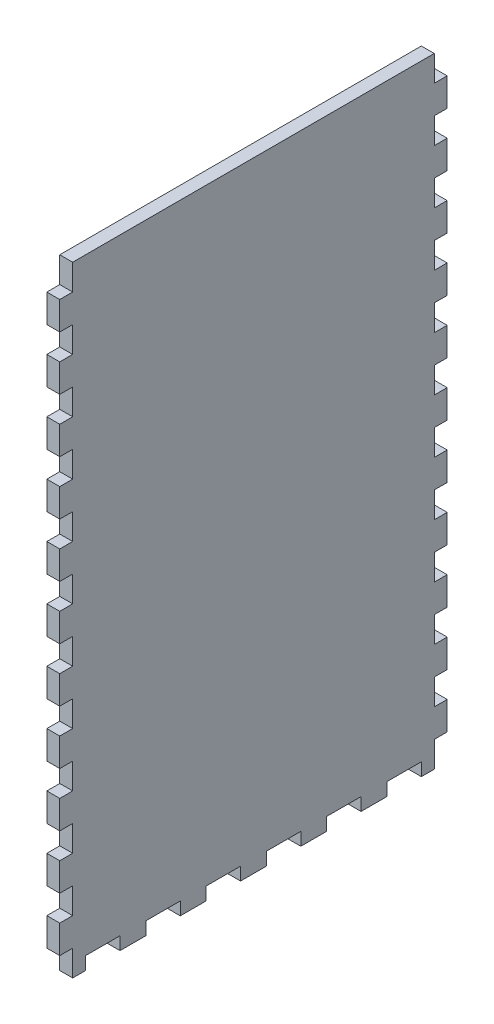
from build123d import *

# Parameters (mm, degrees)
SKETCH1_W           = 508
SKETCH1_H           = 190.5
BOSS_EXTRUDE1_DEPTH = 6.35
SKETCH2_W           = 508
SKETCH2_H           = 190.5
SKETCH2_W_2         = 495.3
SKETCH2_H_2         = 177.8
BOSS_EXTRUDE2_DEPTH = 298.45
SKETCH3_W           = 6.35
SKETCH3_H           = 16.933333333
SKETCH3_H_2         = 16.933333334
CUT_EXTRUDE1_DEPTH  = 12.7
SKETCH4_W           = 6.35
SKETCH4_H           = 15.875
CUT_EXTRUDE2_DEPTH  = 6.35
SKETCH6_W           = 514.801062296
SKETCH6_H           = 254.881465808
CUT_EXTRUDE5_DEPTH  = 305.8
SKETCH5_W           = 6.35
SKETCH5_H           = 16.933333333
SKETCH5_H_2         = 16.933333334
CUT_EXTRUDE6_DEPTH  = 6.35
SKETCH7_W           = 6.35
SKETCH7_H           = 12.7
CUT_EXTRUDE7_DEPTH  = 7.35


with BuildPart() as part:
    # Sketch1 → Boss-Extrude1 (new body)
    with BuildSketch(Plane(origin=(0, 0, 0), x_dir=(1, 0, 0), z_dir=(0, 1, 0))):
        Rectangle(SKETCH1_W, SKETCH1_H)
    extrude(amount=BOSS_EXTRUDE1_DEPTH)

    # Sketch2 → Boss-Extrude2 (add)
    with BuildSketch(Plane(origin=(0, 6.35, 0), x_dir=(1, 0, 0), z_dir=(0, 1, 0))):
        Rectangle(SKETCH2_W, SKETCH2_H)
        Rectangle(SKETCH2_W_2, SKETCH2_H_2, mode=Mode.SUBTRACT)
    extrude(amount=BOSS_EXTRUDE2_DEPTH)

    # Sketch3 → Cut-Extrude1 (cut)
    with BuildSketch(Plane.XY.offset(95.25)):
        with BuildLine():
            Line((-3.302, 283.21), (-3.302, 6.35))
            Line((-3.302, 6.35), (3.302, 6.35))
            Line((3.302, 6.35), (3.302, 292.354))
            Line((3.302, 292.354), (-16.256, 292.354))
            Line((-16.256, 292.354), (-16.256, 285.75))
            Line((-16.256, 285.75), (-5.842, 285.75))
            ThreePointArc((-5.842, 285.75), (-4.045948776, 285.006051224), (-3.302, 283.21))
        make_face()
        with Locations((12.827, 80.433333334)):
            Rectangle(SKETCH3_W, SKETCH3_H)
        with Locations((12.827, 50.8)):
            Rectangle(SKETCH3_W, SKETCH3_H_2)
        with Locations((12.827, 21.166666667)):
            Rectangle(SKETCH3_W, SKETCH3_H)
    extrude(amount=-CUT_EXTRUDE1_DEPTH, mode=Mode.SUBTRACT)

    # Sketch4 → Cut-Extrude2 (cut)
    with BuildSketch(Plane.XY.offset(-88.9)):
        with Locations((-19.431, 284.1625)):
            Rectangle(SKETCH4_W, SKETCH4_H)
        with Locations((-19.431, 255.5875)):
            Rectangle(SKETCH4_W, SKETCH4_H)
        with Locations((-19.431, 227.0125)):
            Rectangle(SKETCH4_W, SKETCH4_H)
        with Locations((-19.431, 198.4375)):
            Rectangle(SKETCH4_W, SKETCH4_H)
        with Locations((-19.431, 169.8625)):
            Rectangle(SKETCH4_W, SKETCH4_H)
        with Locations((-19.431, 141.2875)):
            Rectangle(SKETCH4_W, SKETCH4_H)
        with Locations((-19.431, 112.7125)):
            Rectangle(SKETCH4_W, SKETCH4_H)
        with Locations((-19.431, 84.1375)):
            Rectangle(SKETCH4_W, SKETCH4_H)
        with Locations((-19.431, 55.5625)):
            Rectangle(SKETCH4_W, SKETCH4_H)
        with Locations((-19.431, 26.9875)):
            Rectangle(SKETCH4_W, SKETCH4_H)
    cut_extrude2 = extrude(amount=-CUT_EXTRUDE2_DEPTH, mode=Mode.SUBTRACT)

    # Mirror1: Cut-Extrude2 across plane
    add(cut_extrude2.mirror(Plane.ZY.offset(6.477)), mode=Mode.SUBTRACT)

    # Sketch6 → Cut-Extrude5 (cut, through all)
    with BuildSketch(Plane(origin=(0, 0, 0), x_dir=(1, 0, 0), z_dir=(0, 1, 0))):
        with Locations((9.750531148, -10.000845247)):
            Rectangle(SKETCH6_W, SKETCH6_H)
    extrude(amount=CUT_EXTRUDE5_DEPTH, mode=Mode.SUBTRACT)

    # Sketch5 → Cut-Extrude6 (cut)
    with BuildSketch(Plane(origin=(0, 0, 0), x_dir=(-1, 0, 0), z_dir=(0, -1, 0))):
        with Locations((250.825, -74.083333334)):
            Rectangle(SKETCH5_W, SKETCH5_H)
        with Locations((250.825, -44.45)):
            Rectangle(SKETCH5_W, SKETCH5_H_2)
        with Locations((250.825, -14.816666667)):
            Rectangle(SKETCH5_W, SKETCH5_H)
        with Locations((250.825, 14.816666667)):
            Rectangle(SKETCH5_W, SKETCH5_H)
        with Locations((250.825, 44.45)):
            Rectangle(SKETCH5_W, SKETCH5_H_2)
        with Locations((250.825, 74.083333334)):
            Rectangle(SKETCH5_W, SKETCH5_H)
    extrude(amount=-CUT_EXTRUDE6_DEPTH, mode=Mode.SUBTRACT)

    # Sketch7 → Cut-Extrude7 (cut, through all)
    with BuildSketch(Plane.ZY.offset(254)):
        with Locations((-92.075, 32.904545455)):
            Rectangle(SKETCH7_W, SKETCH7_H)
        with Locations((-92.075, 6.35)):
            Rectangle(SKETCH7_W, SKETCH7_H)
        with Locations((-92.075, 59.459090909)):
            Rectangle(SKETCH7_W, SKETCH7_H)
        with Locations((-92.075, 86.013636364)):
            Rectangle(SKETCH7_W, SKETCH7_H)
        with Locations((-92.075, 112.568181818)):
            Rectangle(SKETCH7_W, SKETCH7_H)
        with Locations((-92.075, 139.122727273)):
            Rectangle(SKETCH7_W, SKETCH7_H)
        with Locations((-92.075, 165.677272727)):
            Rectangle(SKETCH7_W, SKETCH7_H)
        with Locations((-92.075, 192.231818182)):
            Rectangle(SKETCH7_W, SKETCH7_H)
        with Locations((-92.075, 218.786363636)):
            Rectangle(SKETCH7_W, SKETCH7_H)
        with Locations((-92.075, 245.340909091)):
            Rectangle(SKETCH7_W, SKETCH7_H)
        with Locations((-92.075, 271.895454545)):
            Rectangle(SKETCH7_W, SKETCH7_H)
        with Locations((-92.075, 298.45)):
            Rectangle(SKETCH7_W, SKETCH7_H)
        with Locations((92.075, 298.45)):
            Rectangle(SKETCH7_W, SKETCH7_H)
        with Locations((92.075, 271.895454545)):
            Rectangle(SKETCH7_W, SKETCH7_H)
        with Locations((92.075, 245.340909091)):
            Rectangle(SKETCH7_W, SKETCH7_H)
        with Locations((92.075, 218.786363636)):
            Rectangle(SKETCH7_W, SKETCH7_H)
        with Locations((92.075, 192.231818182)):
            Rectangle(SKETCH7_W, SKETCH7_H)
        with Locations((92.075, 165.677272727)):
            Rectangle(SKETCH7_W, SKETCH7_H)
        with Locations((92.075, 139.122727273)):
            Rectangle(SKETCH7_W, SKETCH7_H)
        with Locations((92.075, 112.568181818)):
            Rectangle(SKETCH7_W, SKETCH7_H)
        with Locations((92.075, 86.013636364)):
            Rectangle(SKETCH7_W, SKETCH7_H)
        with Locations((92.075, 59.459090909)):
            Rectangle(SKETCH7_W, SKETCH7_H)
        with Locations((92.075, 32.904545455)):
            Rectangle(SKETCH7_W, SKETCH7_H)
        with Locations((92.075, 6.35)):
            Rectangle(SKETCH7_W, SKETCH7_H)
    extrude(amount=-CUT_EXTRUDE7_DEPTH, mode=Mode.SUBTRACT)


solid = part.part
